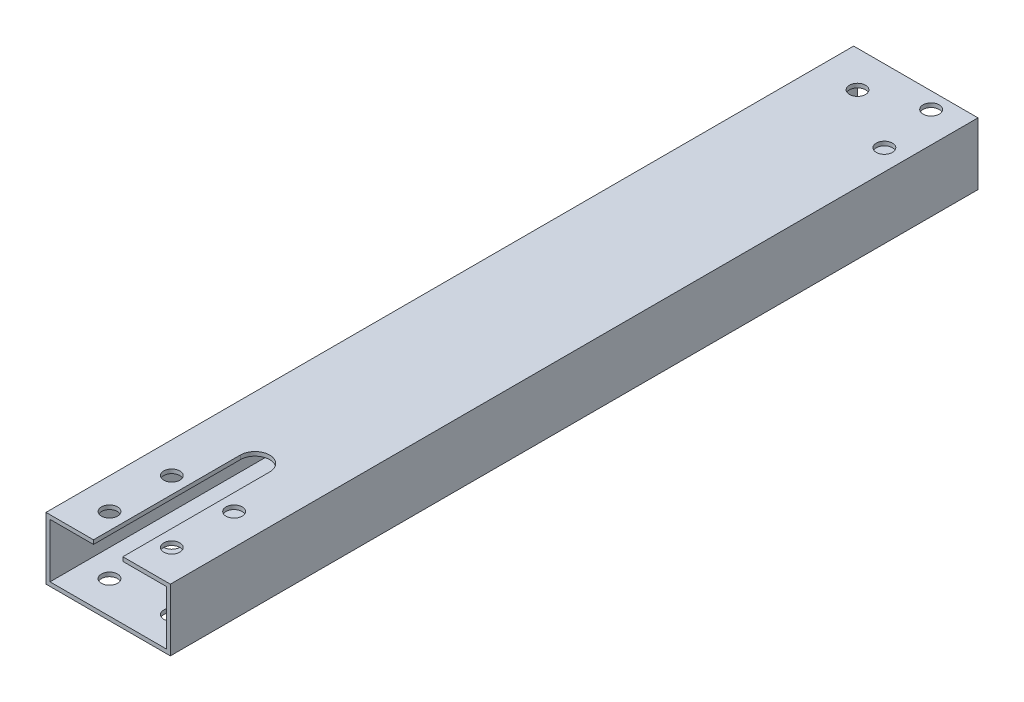
from build123d import *

# Parameters (mm, degrees)
SKETCH1_W              = 50.8
SKETCH1_H              = 25.4
SKETCH1_W_2            = 47.498
SKETCH1_H_2            = 22.098
BOSS_EXTRUDE1_DEPTH    = 330
CUT_EXTRUDE5_REACH     = 27.4
SKETCH8_R              = 3.3
CUT_EXTRUDE6_DEPTH     = 26.4
F_00_CLEARANCE_HOLE1_D = 6.600000008


with BuildPart() as part:
    # Sketch1 → Boss-Extrude1 (new body)
    with BuildSketch(Plane.XY):
        Rectangle(SKETCH1_W, SKETCH1_H)
        Rectangle(SKETCH1_W_2, SKETCH1_H_2, mode=Mode.SUBTRACT)
    extrude(amount=BOSS_EXTRUDE1_DEPTH)

    # Sketch4 → Cut-Extrude5 (cut, up to next)
    with BuildSketch(Plane(origin=(0, 12.7, 0), x_dir=(1, 0, 0), z_dir=(0, 1, 0)), mode=Mode.PRIVATE) as cut_extrude5_sk1:
        with BuildLine():
            Line((-6, -270), (-6, -330))
            Line((-6, -330), (6, -330))
            Line((6, -330), (6, -270))
            ThreePointArc((6, -270), (0, -264), (-6, -270))
        make_face()
    cut_extrude5_tool1 = extrude(cut_extrude5_sk1.sketch, amount=-CUT_EXTRUDE5_REACH, mode=Mode.PRIVATE) & part.part
    add(cut_extrude5_tool1.solids().sort_by_distance((0, 12.7, 297.629949))[0], mode=Mode.SUBTRACT)

    # Sketch8 → Cut-Extrude6 (cut, through all)
    with BuildSketch(Plane(origin=(0, 12.7, 0), x_dir=(1, 0, 0), z_dir=(0, 1, 0))):
        with BuildLine():
            ThreePointArc((-9.427922061, -316.727922061), (-9.679119604, -315.465066735), (-10.394469683, -314.394469683))
            Line((-10.394469683, -314.394469683), (-15.061374439, -319.061374439))
            ThreePointArc((-15.061374439, -319.061374439), (-11.465066735, -319.776724519), (-9.427922061, -316.727922061))
        make_face()
        with BuildLine():
            Line((-15.061374439, -319.061374439), (-10.394469683, -314.394469683))
            ThreePointArc((-10.394469683, -314.394469683), (-15.061374439, -314.394469683), (-15.061374439, -319.061374439))
        make_face()
        with Locations((-12.727922061, -291.272077939)):
            Circle(SKETCH8_R)
        with Locations((12.727922061, -291.272077939)):
            Circle(SKETCH8_R)
        with Locations((12.727922061, -316.727922061)):
            Circle(SKETCH8_R)
    extrude(amount=-CUT_EXTRUDE6_DEPTH, mode=Mode.SUBTRACT)

    # #00 Clearance Hole1 (through all)
    with Locations(Plane(origin=(-99.314776744, 20.7, -27.322532912), x_dir=(0.866025404, 0, 0.5), z_dir=(0, 1, 0))):
        with Locations((99.115053304, 8.695380774), (114.115053304, 26.695380774), (129.115053304, 8.695380774)):
            Hole(F_00_CLEARANCE_HOLE1_D / 2)


solid = part.part
